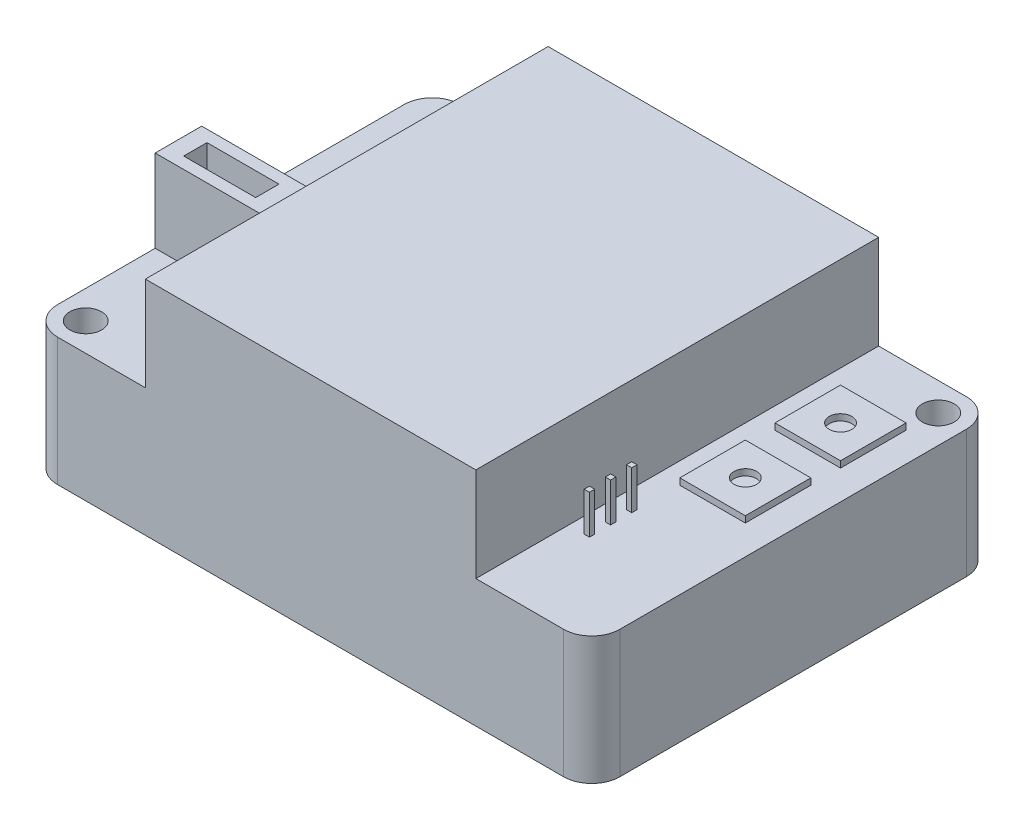
from build123d import *

# Parameters (mm, degrees)
BOSS_EXTRUDE1_DEPTH = 48.3616
FILLET1_R           = 3.3782
SKETCH2_R           = 1.905
CUT_EXTRUDE1_DEPTH  = 85.454628013
SKETCH3_W           = 7.86892
SKETCH3_H           = 7.86892
SKETCH3_R           = 1.35255
BOSS_EXTRUDE2_DEPTH = 0.762
SKETCH4_W           = 12.7
SKETCH4_H           = 5.588
SKETCH4_W_2         = 8.636
SKETCH4_H_2         = 2.794
BOSS_EXTRUDE3_DEPTH = 9.906
SKETCH5_W           = 0.635
SKETCH5_H           = 0.635
BOSS_EXTRUDE4_DEPTH = 4.6736


with BuildPart() as part:
    # Sketch1 → Boss-Extrude1 (new body)
    with BuildSketch(Plane.XY):
        Polygon((0, 0), (67.51574, 0), (67.51574, 15.3416), (53.59908, 15.3416), (53.59908, 26.6446), (13.91666, 26.6446), (13.91666, 15.3416), (0, 15.3416), align=None)
    extrude(amount=-BOSS_EXTRUDE1_DEPTH)

    # Fillet1
    fillet1_edges = [part.edges().sort_by_distance(p)[0] for p in [
        (0, 7.6708, -48.3616),
        (67.51574, 7.6708, -48.3616),
        (67.51574, 7.6708, 0),
        (0, 7.6708, 0),
    ]]
    fillet(fillet1_edges, radius=FILLET1_R)

    # Sketch2 → Cut-Extrude1 (cut, through all)
    with BuildSketch(Plane(origin=(0, 15.3416, 0), x_dir=(1, 0, 0), z_dir=(0, 1, 0))):
        with Locations((3.3782, 3.3782)):
            Circle(SKETCH2_R)
        with Locations((64.13754, 44.9834)):
            Circle(SKETCH2_R)
    extrude(amount=-CUT_EXTRUDE1_DEPTH, mode=Mode.SUBTRACT)

    # Sketch3 → Boss-Extrude2 (add)
    # profile 1 of 4: a face of its own
    with BuildSketch(Plane(origin=(0, 15.3416, 0), x_dir=(1, 0, 0), z_dir=(0, 1, 0))):
        with Locations((60.06592, 25.88768)):
            Rectangle(SKETCH3_W, SKETCH3_H)
        with Locations((60.06592, 25.88768)):
            Circle(SKETCH3_R, mode=Mode.SUBTRACT)
    # profile 2 of 4: a face of its own
    with BuildSketch(Plane(origin=(0, 15.3416, 0), x_dir=(1, 0, 0), z_dir=(0, 1, 0))):
        with Locations((7.44982, 37.31768)):
            Rectangle(SKETCH3_W, SKETCH3_H)
        with Locations((7.44982, 37.31768)):
            Circle(SKETCH3_R, mode=Mode.SUBTRACT)
    # profile 3 of 4: a face of its own
    with BuildSketch(Plane(origin=(0, 15.3416, 0), x_dir=(1, 0, 0), z_dir=(0, 1, 0))):
        with Locations((7.44982, 25.88768)):
            Rectangle(SKETCH3_W, SKETCH3_H)
        with Locations((7.44982, 25.88768)):
            Circle(SKETCH3_R, mode=Mode.SUBTRACT)
    # profile 4 of 4: a face of its own
    with BuildSketch(Plane(origin=(0, 15.3416, 0), x_dir=(1, 0, 0), z_dir=(0, 1, 0))):
        with Locations((60.06592, 37.31768)):
            Rectangle(SKETCH3_W, SKETCH3_H)
        with Locations((60.06592, 37.31768)):
            Circle(SKETCH3_R, mode=Mode.SUBTRACT)
    extrude(amount=BOSS_EXTRUDE2_DEPTH)

    # Sketch4 → Boss-Extrude3 (add)
    with BuildSketch(Plane(origin=(0, 15.3416, 0), x_dir=(1, 0, 0), z_dir=(0, 1, 0))):
        with Locations((6.35, 17.88922)):
            Rectangle(SKETCH4_W, SKETCH4_H)
        with Locations((6.35, 17.88922)):
            Rectangle(SKETCH4_W_2, SKETCH4_H_2, mode=Mode.SUBTRACT)
    extrude(amount=BOSS_EXTRUDE3_DEPTH)

    # Sketch5 → Boss-Extrude4 (add)
    with BuildSketch(Plane(origin=(0, 15.3416, 0), x_dir=(1, 0, 0), z_dir=(0, 1, 0))):
        with Locations((55.79618, 16.52016)):
            Rectangle(SKETCH5_W, SKETCH5_H)
        with Locations((55.79618, 13.98016)):
            Rectangle(SKETCH5_W, SKETCH5_H)
        with Locations((55.79618, 11.44016)):
            Rectangle(SKETCH5_W, SKETCH5_H)
    extrude(amount=BOSS_EXTRUDE4_DEPTH)


solid = part.part
